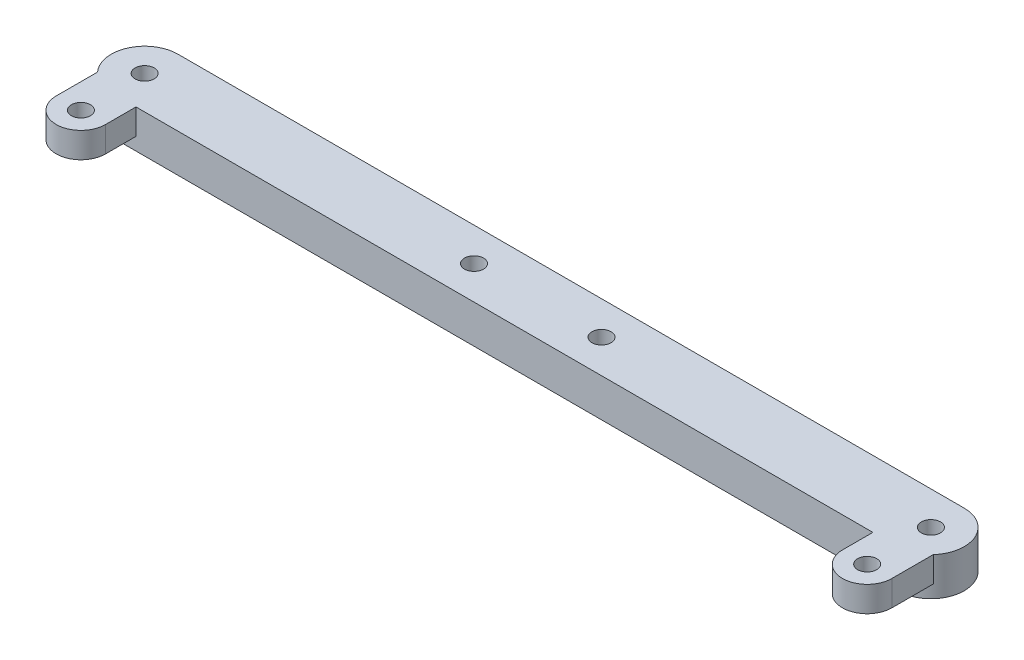
from build123d import *

# Parameters (mm, degrees)
SKETCH1_R           = 1.5
BOSS_EXTRUDE1_DEPTH = 6
SKETCH2_R           = 1.5
BOSS_EXTRUDE2_DEPTH = 4
SKETCH3_R           = 1.5
CUT_EXTRUDE1_DEPTH  = 10


with BuildPart() as part:
    # Sketch1 → Boss-Extrude1 (new body)
    with BuildSketch(Plane(origin=(0, 0, 0), x_dir=(1, 0, 0), z_dir=(0, 1, 0))):
        with BuildLine():
            Line((0, 5.230556007), (123.36, 5.230556007))
            ThreePointArc((123.36, 5.230556007), (128.590556007, 0), (123.36, -5.230556007))
            Line((123.36, -5.230556007), (0, -5.230556007))
            ThreePointArc((0, -5.230556007), (-5.230556007, 0), (0, 5.230556007))
        make_face()
        Circle(SKETCH1_R, mode=Mode.SUBTRACT)
        with Locations((123.36, 0)):
            Circle(SKETCH1_R, mode=Mode.SUBTRACT)
    extrude(amount=BOSS_EXTRUDE1_DEPTH)

    # Sketch2 → Boss-Extrude2 (add)
    with BuildSketch(Plane(origin=(0, 6, 0), x_dir=(1, 0, 0), z_dir=(0, 1, 0))):
        with BuildLine():
            Line((3.876609724, 0), (3.876609724, -10))
            ThreePointArc((3.876609724, -10), (0, -13.876609724), (-3.876609724, -10))
            Line((-3.876609724, -10), (-3.876609724, 0))
            ThreePointArc((-3.876609724, 0), (0, 3.876609724), (3.876609724, 0))
        make_face()
        with Locations((0, -10)):
            Circle(SKETCH2_R, mode=Mode.SUBTRACT)
        Circle(SKETCH2_R, mode=Mode.SUBTRACT)
        with BuildLine():
            Line((119.483390276, 0), (119.483390276, -10))
            ThreePointArc((119.483390276, -10), (123.36, -13.876609724), (127.236609724, -10))
            Line((127.236609724, -10), (127.236609724, 0))
            ThreePointArc((127.236609724, 0), (123.36, 3.876609724), (119.483390276, 0))
        make_face()
        with Locations((123.36, 0)):
            Circle(SKETCH2_R, mode=Mode.SUBTRACT)
        with Locations((123.36, -10)):
            Circle(SKETCH2_R, mode=Mode.SUBTRACT)
    extrude(amount=-BOSS_EXTRUDE2_DEPTH)

    # Sketch3 → Cut-Extrude1 (cut)
    with BuildSketch(Plane(origin=(0, 6, 0), x_dir=(1, 0, 0), z_dir=(0, 1, 0))):
        with Locations((51.68, 0)):
            Circle(SKETCH3_R)
        with Locations((71.68, 0)):
            Circle(SKETCH3_R)
    extrude(amount=-CUT_EXTRUDE1_DEPTH, mode=Mode.SUBTRACT)


solid = part.part
